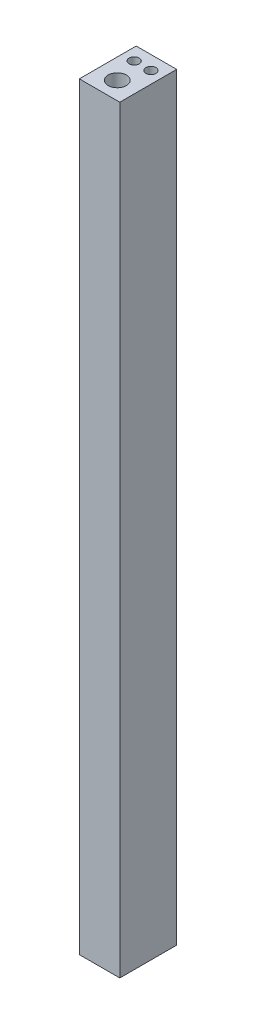
from build123d import *

# Parameters (mm, degrees)
SKETCH2_W           = 3.2
SKETCH2_H           = 4.5
BOSS_EXTRUDE1_DEPTH = 59.999999888
SKETCH5_R           = 0.724999947
CUT_EXTRUDE1_DEPTH  = 60.999999888
SKETCH6_R           = 0.399999962
CUT_EXTRUDE2_DEPTH  = 60.999999888
SKETCH7_R           = 0.4
CUT_EXTRUDE3_DEPTH  = 60.999999888


with BuildPart() as part:
    # Sketch2 → Boss-Extrude1 (new body)
    with BuildSketch(Plane(origin=(0, 0, 0), x_dir=(1, 0, 0), z_dir=(0, 1, 0))):
        Rectangle(SKETCH2_W, SKETCH2_H)
    extrude(amount=BOSS_EXTRUDE1_DEPTH)

    # Sketch5 → Cut-Extrude1 (cut, through all)
    with BuildSketch(Plane(origin=(0, 59.999999888, 0), x_dir=(-1, 0, 0), z_dir=(0, 1, 0))):
        with Locations(Location((0, 0.849563353, 0), (0, 0, 90))):  # turned: the seam where the file's is
            Circle(SKETCH5_R)
    extrude(amount=-CUT_EXTRUDE1_DEPTH, mode=Mode.SUBTRACT)

    # Sketch6 → Cut-Extrude2 (cut, through all)
    with BuildSketch(Plane(origin=(0, 59.999999888, 0), x_dir=(-1, 0, 0), z_dir=(0, 1, 0))):
        with Locations(Location((0.656880529, -1.145056402, 0), (0, 0, 90))):  # turned: the seam where the file's is
            Circle(SKETCH6_R)
    extrude(amount=-CUT_EXTRUDE2_DEPTH, mode=Mode.SUBTRACT)

    # Sketch7 → Cut-Extrude3 (cut, through all)
    with BuildSketch(Plane(origin=(0, 59.999999888, 0), x_dir=(-1, 0, 0), z_dir=(0, 1, 0))):
        with Locations(Location((-0.657995536, -1.153321844, 0), (0, 0, 90))):  # turned: the seam where the file's is
            Circle(SKETCH7_R)
    extrude(amount=-CUT_EXTRUDE3_DEPTH, mode=Mode.SUBTRACT)


solid = part.part
